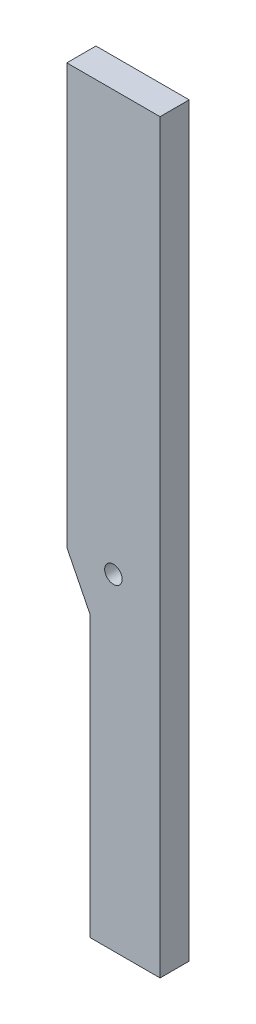
from build123d import *

# Parameters (mm, degrees)
SKETCH1_W           = 50.8
SKETCH1_H           = 254
BOSS_EXTRUDE1_DEPTH = 15.875
CHAMFER1_SIZE       = 25.4
CHAMFER1_SIZE2      = 12.7
SKETCH2_R           = 4.7625
CUT_EXTRUDE1_DEPTH  = 16.875
SKETCH3_W           = 38.1
SKETCH3_H           = 152.4
BOSS_EXTRUDE2_DEPTH = 15.875


with BuildPart() as part:
    # Sketch1 → Boss-Extrude1 (new body)
    with BuildSketch(Plane.XY):
        with Locations((25.4, 127)):
            Rectangle(SKETCH1_W, SKETCH1_H)
    extrude(amount=BOSS_EXTRUDE1_DEPTH)

    # Chamfer1
    chamfer1_edges = [part.edges().sort_by_distance(p)[0] for p in [
        (0, 0, 7.9375),
    ]]
    chamfer1_side = [part.faces().sort_by_distance(p)[0] for p in [
        (0, 127, 7.9375),
    ]]
    chamfer(chamfer1_edges, length=CHAMFER1_SIZE, length2=CHAMFER1_SIZE2, reference=chamfer1_side[0])

    # Sketch2 → Cut-Extrude1 (cut, through all)
    with BuildSketch(Plane.XY.offset(15.875)):
        with Locations((25.4, 25.4)):
            Circle(SKETCH2_R)
    extrude(amount=-CUT_EXTRUDE1_DEPTH, mode=Mode.SUBTRACT)

    # Sketch3 → Boss-Extrude2 (add)
    with BuildSketch(Plane.XY.offset(15.875)):
        with Locations((31.75, -76.2)):
            Rectangle(SKETCH3_W, SKETCH3_H)
    extrude(amount=-BOSS_EXTRUDE2_DEPTH)


solid = part.part
